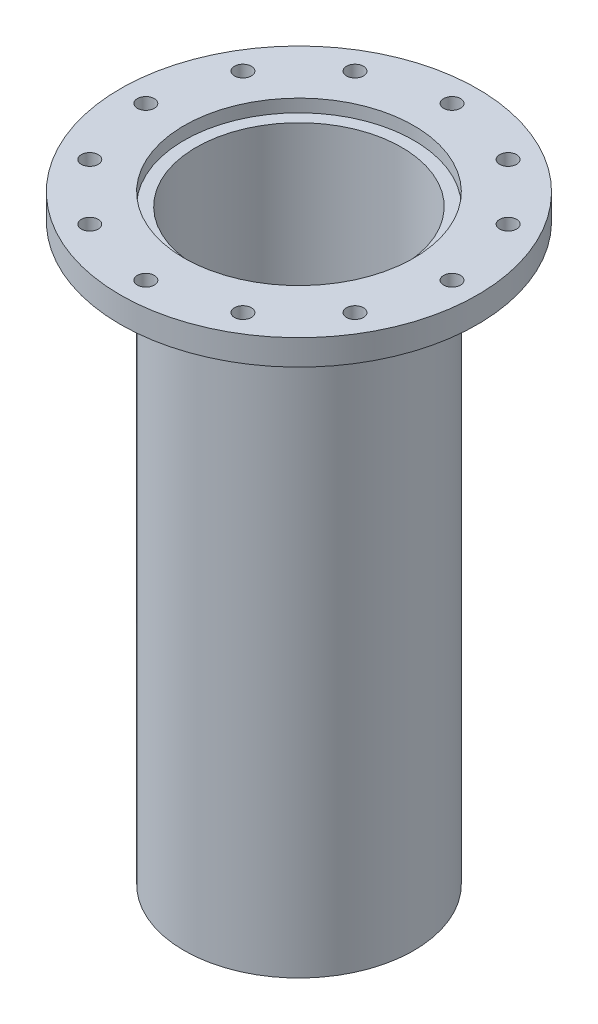
from build123d import *

# Parameters (mm, degrees)
F_5_16_CLEARANCE_HOLE1_D = 8.4328
CIRPATTERN1_COUNT        = 12


with BuildPart() as part:
    # Sketch1 → Revolve1 (revolve)
    with BuildSketch(Plane.XY):
        Polygon((-57.15, 0), (-88.9, 0), (-88.9, -12.7), (-57.15, -12.7), (-57.15, -298.45), (-51.1302, -298.45), (-51.1302, -6.35), (-57.15, -6.35), align=None)
    revolve(axis=Axis((0, 0, 0), (0, -1, 0)))

    # 5/16 Clearance Hole1 (through all)
    with Locations(Plane(origin=(0, 0, 0), x_dir=(1, 0, 0), z_dir=(0, 1, 0))):
        with Locations((-76.2, 0)):
            f_5_16_clearance_hole1 = Hole(F_5_16_CLEARANCE_HOLE1_D / 2)

    # CirPattern1: 5/16 Clearance Hole1 ×12 about axis
    cirpattern1_axis = Axis((0, 0, 0), (0, 1, 0))
    for i in range(1, CIRPATTERN1_COUNT):
        add(f_5_16_clearance_hole1.rotate(cirpattern1_axis, i * 360 / CIRPATTERN1_COUNT), mode=Mode.SUBTRACT)


solid = part.part
